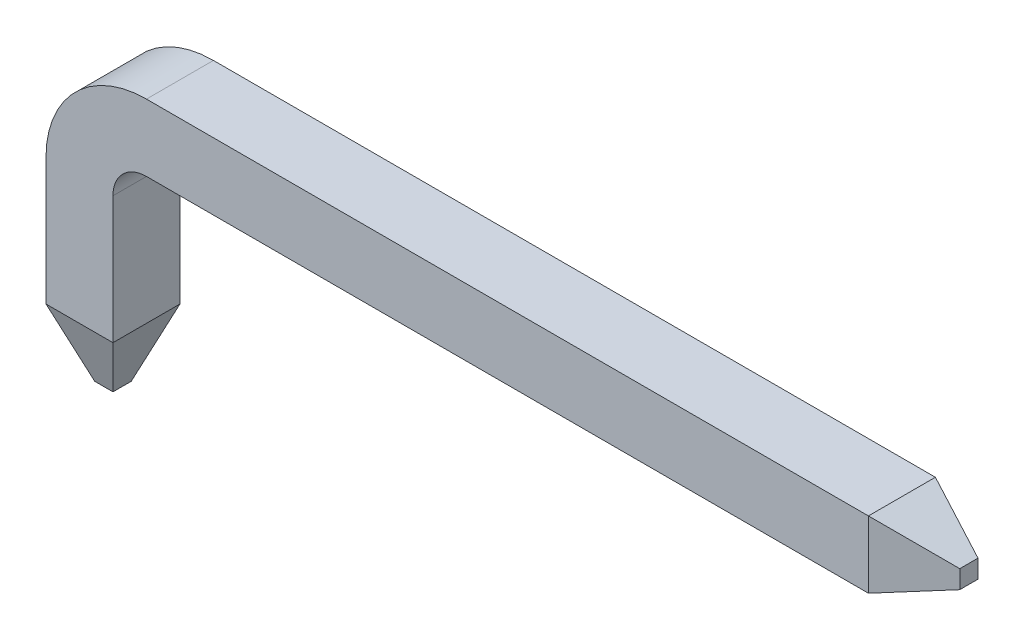
from build123d import *

# Parameters (mm, degrees)
SKETCH1_W           = 0.5
SKETCH1_H           = 0.5
SKETCH6_W           = 0.5
SKETCH6_H           = 0.5
BOSS_EXTRUDE1_DEPTH = 0.5
BOSS_EXTRUDE1_TAPER = 20
SKETCH7_W           = 0.5
SKETCH7_H           = 0.5
BOSS_EXTRUDE2_DEPTH = 0.5
BOSS_EXTRUDE2_TAPER = 20


with BuildPart() as part:
    # Sweep4: sweep along a path in Sketch2
    with BuildLine(Plane.XY) as sweep4_path:
        Line((0.25, 0), (0.25, 0.95))
        ThreePointArc((0.25, 0.95), (0.396446609, 1.303553391), (0.75, 1.45))
        Line((0.75, 1.45), (6.14, 1.45))
    # Sketch1 → Sweep4 (sweep)
    with BuildSketch(Plane(origin=(0, 0, 0), x_dir=(1, 0, 0), z_dir=(0, 1, 0))):
        with Locations((0.25, 0.25)):
            Rectangle(SKETCH1_W, SKETCH1_H)
    sweep(path=sweep4_path.line)

    # Sketch6 → Boss-Extrude1 (add)
    with BuildSketch(Plane(origin=(6.14, 0, 0), x_dir=(0, 0, -1), z_dir=(1, 0, 0))):
        with Locations((0.25, 1.45)):
            Rectangle(SKETCH6_W, SKETCH6_H)
    extrude(amount=BOSS_EXTRUDE1_DEPTH, taper=BOSS_EXTRUDE1_TAPER)

    # Sketch7 → Boss-Extrude2 (add)
    with BuildSketch(Plane.XZ):
        with Locations((0.25, -0.25)):
            Rectangle(SKETCH7_W, SKETCH7_H)
    extrude(amount=BOSS_EXTRUDE2_DEPTH, taper=BOSS_EXTRUDE2_TAPER)


solid = part.part
